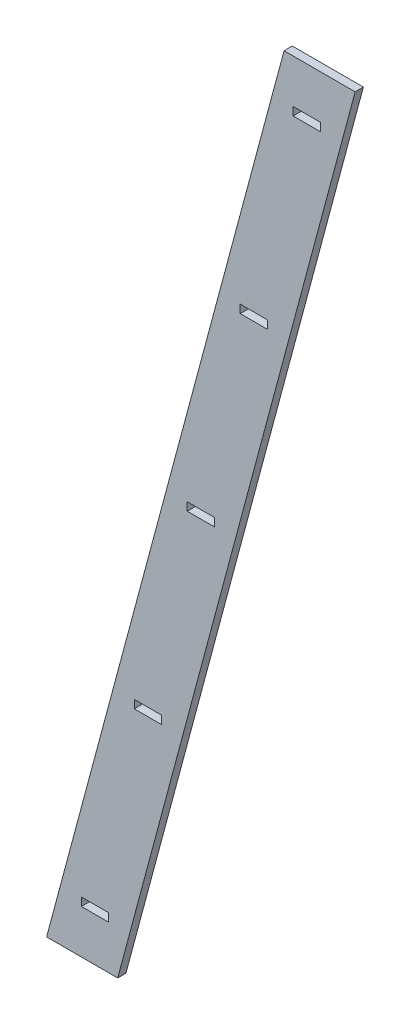
from build123d import *

# Parameters (mm, degrees)
CROQUIS1_W              = 50
CROQUIS1_H              = 15
SALIENTE_EXTRUIR1_DEPTH = 15


with BuildPart() as part:
    # Croquis1 → Saliente-Extruir1 (new body)
    with BuildSketch(Plane.XY):
        Polygon((273.330497115, 777.5), (-152.038845869, -810), (-282.038845869, -810), (-273.330497115, -777.5), (152.038845869, 810), (282.038845869, 810), align=None)
        Rectangle(CROQUIS1_W, CROQUIS1_H, mode=Mode.SUBTRACT)
        with Locations((-193.593291531, -722.5)):
            Rectangle(CROQUIS1_W, CROQUIS1_H, mode=Mode.SUBTRACT)
        with Locations((-96.796645766, -361.25)):
            Rectangle(CROQUIS1_W, CROQUIS1_H, mode=Mode.SUBTRACT)
        with Locations((96.796645766, 361.25)):
            Rectangle(CROQUIS1_W, CROQUIS1_H, mode=Mode.SUBTRACT)
        with Locations((193.593291531, 722.5)):
            Rectangle(CROQUIS1_W, CROQUIS1_H, mode=Mode.SUBTRACT)
    extrude(amount=SALIENTE_EXTRUIR1_DEPTH)


solid = part.part
